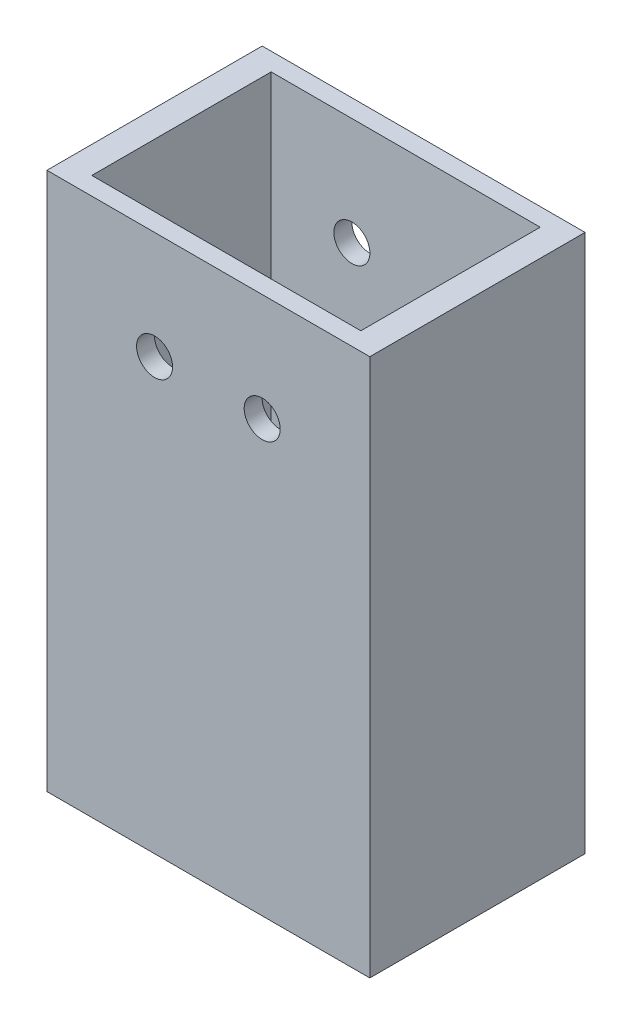
from build123d import *

# Parameters (mm, degrees)
SKETCH1_W                    = 76.2
SKETCH1_H                    = 50.8
SKETCH1_W_2                  = 63.5
SKETCH1_H_2                  = 42.333333334
BOSS_EXTRUDE1_DEPTH          = 63.5
TAP_DRILL_FOR_M10X1_5_TAP1_D = 8.5


with BuildPart() as part:
    # Sketch1 → Boss-Extrude1 (new body, symmetric)
    with BuildSketch(Plane(origin=(0, 0, 0), x_dir=(1, 0, 0), z_dir=(0, 1, 0))):
        Rectangle(SKETCH1_W, SKETCH1_H)
        Rectangle(SKETCH1_W_2, SKETCH1_H_2, mode=Mode.SUBTRACT)
    extrude(amount=BOSS_EXTRUDE1_DEPTH, both=True)

    # Tap Drill for M10x1.5 Tap1 (through all)
    with Locations(Plane.XY.offset(25.4)):
        with Locations((-12.7, 38.1), (12.7, 38.1)):
            Hole(TAP_DRILL_FOR_M10X1_5_TAP1_D / 2)


solid = part.part
